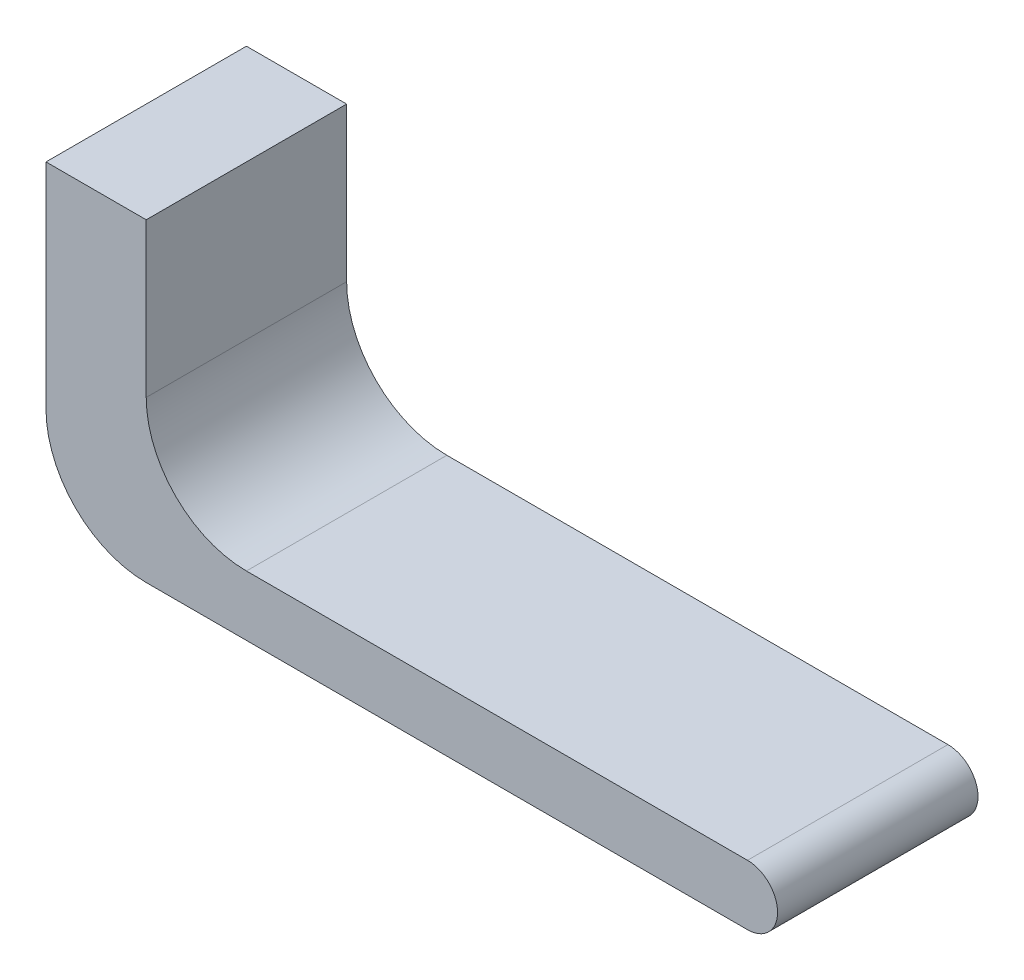
from build123d import *

# Parameters (mm, degrees)
EXTRUDE_1_DEPTH = 10
FILLET_1_R      = 5


with BuildPart() as part:
    # 草图1 → 凸台-拉伸1 (new body)
    with BuildSketch(Plane.XY):
        with BuildLine():
            Line((0, -1.5), (-30, -1.5))
            Line((-30, -1.5), (-35, -1.5))
            Line((-35, -1.5), (-35, 14.176056338))
            Line((-35, 14.176056338), (-30, 14.176056338))
            Line((-30, 14.176056338), (-30, 6.5))
            ThreePointArc((-30, 6.5), (-28.535533906, 2.964466094), (-25, 1.5))
            Line((-25, 1.5), (0, 1.5))
            ThreePointArc((0, 1.5), (1.5, 0), (0, -1.5))
        make_face()
    extrude(amount=EXTRUDE_1_DEPTH)

    # 圆角1
    fillet_1_edges = [part.edges().sort_by_distance(p)[0] for p in [
        (-35, -1.5, 5),
    ]]
    fillet(fillet_1_edges, radius=FILLET_1_R)


solid = part.part
